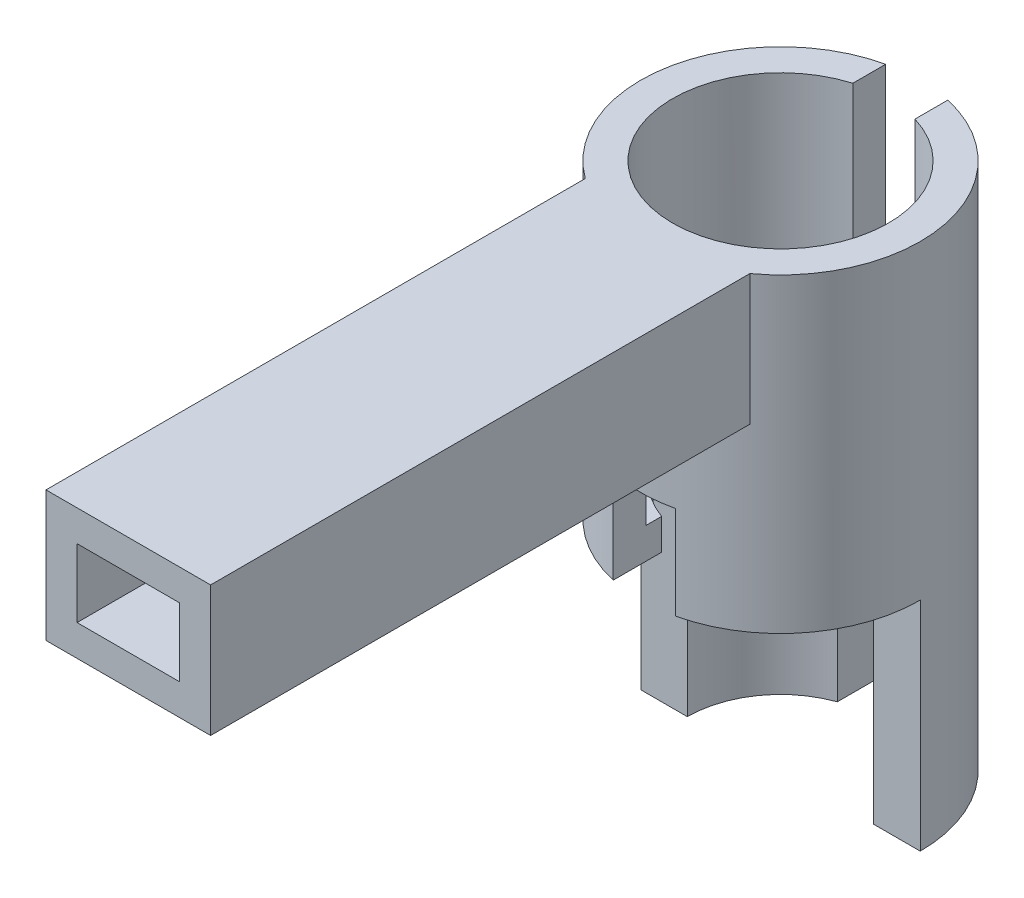
from build123d import *

# Parameters (mm, degrees)
SKETCH5_R                = 4.5
BOSS_EXTRUDE2_DEPTH      = 17
SKETCH6_R                = 3.475
CUT_EXTRUDE2_DEPTH       = 9
SKETCH7_R                = 3
CUT_EXTRUDE3_DEPTH       = 9
SKETCH8_W                = 5.3
SKETCH8_H                = 4.2
BOSS_EXTRUDE3_DEPTH      = 18
SKETCH9_W                = 3.3
SKETCH9_H                = 2.2
CUT_EXTRUDE7_DEPTH       = 20
SKETCH22_W               = 2
SKETCH22_H               = 4.219602282
CUT_EXTRUDE17_DEPTH      = 10
SKETCH23_W               = 15.323048642
SKETCH23_H               = 5.208319784
CUT_EXTRUDE18_DEPTH      = 7
SKETCH24_W               = 2
SKETCH24_H               = 5.427023282
CUT_EXTRUDE19_DEPTH      = 18
CUT_EXTRUDE19_DEPTH_BACK = 1
SKETCH26_R               = 3.475
CUT_EXTRUDE21_DEPTH      = 7


with BuildPart() as part:
    # Sketch5 → Boss-Extrude2 (new body)
    with BuildSketch(Plane(origin=(0, 0, 0), x_dir=(1, 0, 0), z_dir=(0, 1, 0))):
        Circle(SKETCH5_R)
    extrude(amount=BOSS_EXTRUDE2_DEPTH)

    # Sketch6 → Cut-Extrude2 (cut)
    with BuildSketch(Plane(origin=(0, 17, 0), x_dir=(1, 0, 0), z_dir=(0, 1, 0))):
        Circle(SKETCH6_R)
    extrude(amount=-CUT_EXTRUDE2_DEPTH, mode=Mode.SUBTRACT)

    # Sketch7 → Cut-Extrude3 (cut, through all)
    with BuildSketch(Plane(origin=(0, 8, 0), x_dir=(1, 0, 0), z_dir=(0, 1, 0))):
        Circle(SKETCH7_R)
    extrude(amount=-CUT_EXTRUDE3_DEPTH, mode=Mode.SUBTRACT)

    # Sketch8 → Boss-Extrude3 (add)
    with BuildSketch(Plane.XY.offset(3)):
        with Locations((0, 14.9)):
            Rectangle(SKETCH8_W, SKETCH8_H)
    extrude(amount=BOSS_EXTRUDE3_DEPTH)

    # Sketch9 → Cut-Extrude7 (cut)
    with BuildSketch(Plane.XY.offset(21)):
        with Locations((0, 14.9)):
            Rectangle(SKETCH9_W, SKETCH9_H)
    extrude(amount=-CUT_EXTRUDE7_DEPTH, mode=Mode.SUBTRACT)

    # Sketch22 → Cut-Extrude17 (cut)
    with BuildSketch(Plane(origin=(0, 0, 0), x_dir=(1, 0, 0), z_dir=(0, 1, 0))):
        with Locations((0, -4.5)):
            Rectangle(SKETCH22_W, SKETCH22_H)
    extrude(amount=CUT_EXTRUDE17_DEPTH, mode=Mode.SUBTRACT)

    # Sketch23 → Cut-Extrude18 (cut)
    with BuildSketch(Plane(origin=(0, 0, 0), x_dir=(1, 0, 0), z_dir=(0, 1, 0))):
        with Locations((-0.238082605, -2.604159892)):
            Rectangle(SKETCH23_W, SKETCH23_H)
    extrude(amount=CUT_EXTRUDE18_DEPTH, mode=Mode.SUBTRACT)

    # Sketch24 → Cut-Extrude19 (cut, two sides)
    with BuildSketch(Plane(origin=(0, 0, 0), x_dir=(1, 0, 0), z_dir=(0, 1, 0))) as cut_extrude19_sk:
        with Locations((0, 4.5)):
            Rectangle(SKETCH24_W, SKETCH24_H)
    extrude(amount=CUT_EXTRUDE19_DEPTH, mode=Mode.SUBTRACT)
    extrude(cut_extrude19_sk.sketch, amount=-CUT_EXTRUDE19_DEPTH_BACK, mode=Mode.SUBTRACT)

    # Sketch26 → Cut-Extrude21 (cut)
    with BuildSketch(Plane(origin=(0, 17, 0), x_dir=(1, 0, 0), z_dir=(0, 1, 0))):
        Circle(SKETCH26_R)
    extrude(amount=-CUT_EXTRUDE21_DEPTH, mode=Mode.SUBTRACT)


solid = part.part
